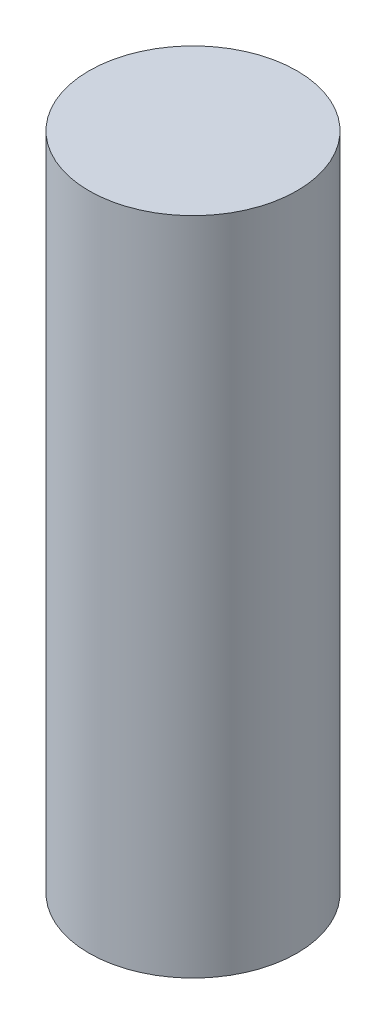
from build123d import *

# Parameters (mm, degrees)
SKETCH1_R           = 2
BOSS_EXTRUDE1_DEPTH = 12.7


with BuildPart() as part:
    # Sketch1 → Boss-Extrude1 (new body)
    with BuildSketch(Plane(origin=(0, 0, 0), x_dir=(1, 0, 0), z_dir=(0, 1, 0))):
        Circle(SKETCH1_R)
    extrude(amount=BOSS_EXTRUDE1_DEPTH)


solid = part.part
